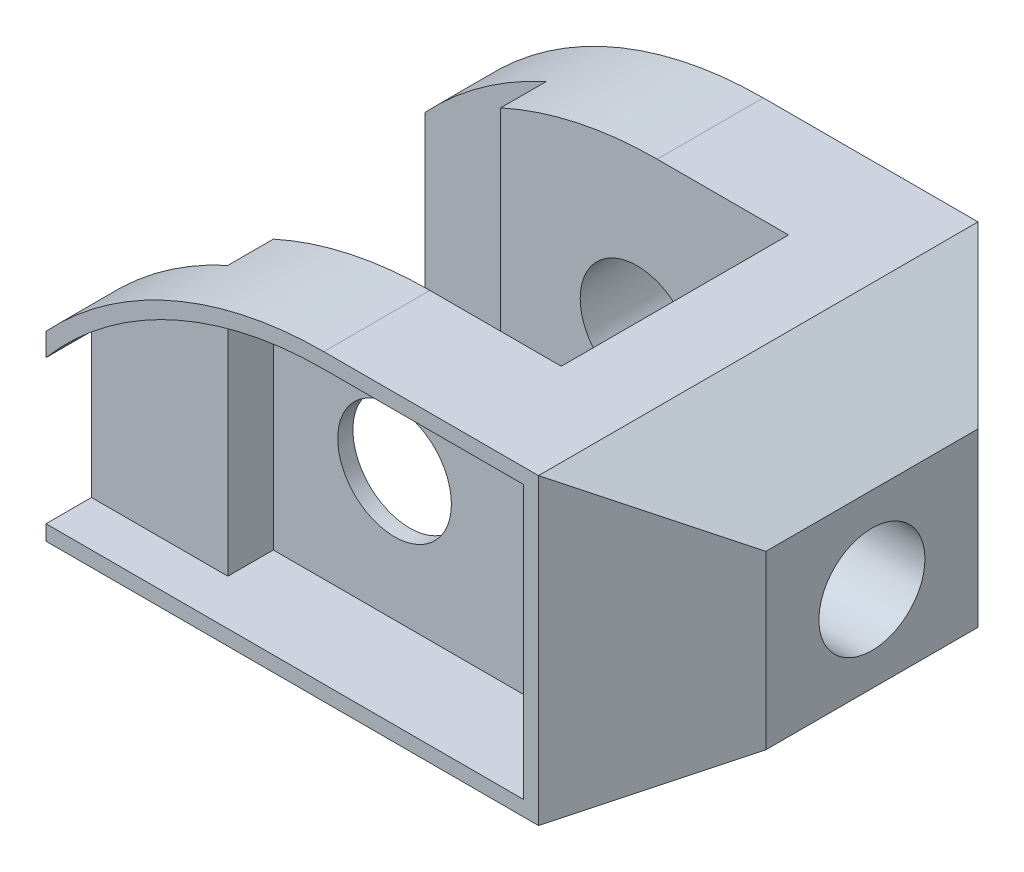
from build123d import *

# Parameters (mm, degrees)
SKETCH1_R           = 7.5
BOSS_EXTRUDE1_DEPTH = 58
CUT_EXTRUDE1_REACH  = 86.143
CUT_EXTRUDE2_REACH  = 103.02
SKETCH3_R           = 7
CHAMFER1_SIZE       = 15
CUT_EXTRUDE3_DEPTH  = 6
CUT_EXTRUDE4_START  = -12
SKETCH4_3_R         = 7.5
CUT_EXTRUDE4_DEPTH  = 12


with BuildPart() as part:
    # Sketch1 → Boss-Extrude1 (new body)
    with BuildSketch(Plane.XY):
        with BuildLine():
            Line((-34, -19), (31, -19))
            Line((31, -19), (46, -10.339745962))
            Line((46, -10.339745962), (46, 12.339745962))
            Line((46, 12.339745962), (31, 21))
            Line((31, 21), (2.66060556, 21))
            ThreePointArc((2.66060556, 21), (-17.33939444, 16.82575695), (-34, 5))
            Line((-34, 5), (-34, -19))
        make_face()
        Circle(SKETCH1_R, mode=Mode.SUBTRACT)
    extrude(amount=BOSS_EXTRUDE1_DEPTH)

    # Sketch2 → Cut-Extrude1 (cut, up to next)
    with BuildSketch(Plane.XZ.offset(19), mode=Mode.PRIVATE) as cut_extrude1_sk1:
        Polygon((-34, 50), (-18, 50), (-18, 44), (20, 44), (20, 14), (-18, 14), (-18, 8), (-34, 8), align=None)
    cut_extrude1_tool1 = extrude(cut_extrude1_sk1.sketch, amount=-CUT_EXTRUDE1_REACH, mode=Mode.PRIVATE) & part.part
    add(cut_extrude1_tool1.solids().sort_by_distance((-9.013245, -19, 29))[0], mode=Mode.SUBTRACT)

    # Sketch3 → Cut-Extrude2 (cut, up to next)
    with BuildSketch(Plane(origin=(46, 0, 0), x_dir=(0, 0, -1), z_dir=(1, 0, 0)), mode=Mode.PRIVATE) as cut_extrude2_sk1:
        with Locations((-29, 1)):
            Circle(SKETCH3_R)
    cut_extrude2_tool1 = extrude(cut_extrude2_sk1.sketch, amount=-CUT_EXTRUDE2_REACH, mode=Mode.PRIVATE) & part.part
    add(cut_extrude2_tool1.solids().sort_by_distance((46, 1, 29))[0], mode=Mode.SUBTRACT)

    # Chamfer1
    chamfer1_edges = [part.edges().sort_by_distance(p)[0] for p in [
        (46, 1, 0),
        (46, 1, 58),
    ]]
    chamfer(chamfer1_edges, length=CHAMFER1_SIZE)

    # Sketch4 → Cut-Extrude3 (cut)
    with BuildSketch(Plane.XY.offset(58)):
        with BuildLine():
            ThreePointArc((-32.533575778, 3.64), (-33.2763294, 2.820381922), (-34, 1.98386677))
            Line((-34, 1.98386677), (-34, -17))
            Line((-34, -17), (-16, -17))
            Line((-16, -17), (-16, 15.224221872))
            ThreePointArc((-16, 15.224221872), (-24.882688852, 10.311155325), (-32.533575778, 3.64))
        make_face()
    extrude(amount=-CUT_EXTRUDE3_DEPTH, mode=Mode.SUBTRACT)

    # Sketch4_3 → Cut-Extrude4 (cut)
    with BuildSketch(Plane.XY.offset(58).offset(CUT_EXTRUDE4_START)):
        with BuildLine():
            Line((-16, 15.224221872), (-16, -17))
            Line((-16, -17), (29, -17))
            Line((29, -17), (29, 19))
            Line((29, 19), (2.66060556, 19))
            ThreePointArc((2.66060556, 19), (-6.858778616, 18.046586751), (-16, 15.224221872))
        make_face()
        Circle(SKETCH4_3_R, mode=Mode.SUBTRACT)
    extrude(amount=CUT_EXTRUDE4_DEPTH, mode=Mode.SUBTRACT)


solid = part.part
